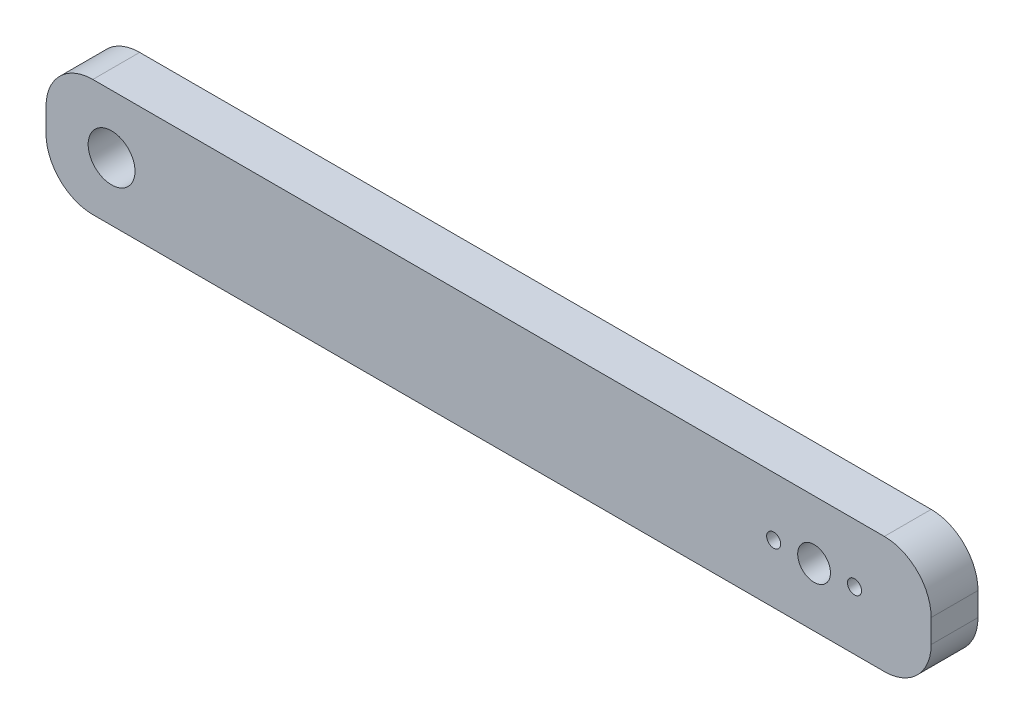
from build123d import *

# Parameters (mm, degrees)
SKETCH1_R           = 5
SKETCH1_R_2         = 3.5
SKETCH1_R_3         = 1.5
BOSS_EXTRUDE1_DEPTH = 10


with BuildPart() as part:
    # Sketch1 → Boss-Extrude1 (new body)
    with BuildSketch(Plane.XY):
        with BuildLine():
            Line((0, 0), (-90.847457627, 0))
            ThreePointArc((-90.847457627, 0), (-97.918525439, -2.928932188), (-100.847457627, -10))
            Line((-100.847457627, -10), (-100.847457627, -15))
            ThreePointArc((-100.847457627, -15), (-97.918525439, -22.071067812), (-90.847457627, -25))
            Line((-90.847457627, -25), (78.152542373, -25))
            ThreePointArc((78.152542373, -25), (85.223610185, -22.071067812), (88.152542373, -15))
            Line((88.152542373, -15), (88.152542373, -10))
            ThreePointArc((88.152542373, -10), (85.223610185, -2.928932188), (78.152542373, 0))
            Line((78.152542373, 0), (0, 0))
        make_face()
        with Locations((-86.847457627, -12.5)):
            Circle(SKETCH1_R, mode=Mode.SUBTRACT)
        with Locations((63.152542373, -12.5)):
            Circle(SKETCH1_R_2, mode=Mode.SUBTRACT)
        with Locations((54.522542373, -12.5)):
            Circle(SKETCH1_R_3, mode=Mode.SUBTRACT)
        with Locations((71.782542373, -12.5)):
            Circle(SKETCH1_R_3, mode=Mode.SUBTRACT)
    extrude(amount=BOSS_EXTRUDE1_DEPTH)


solid = part.part
